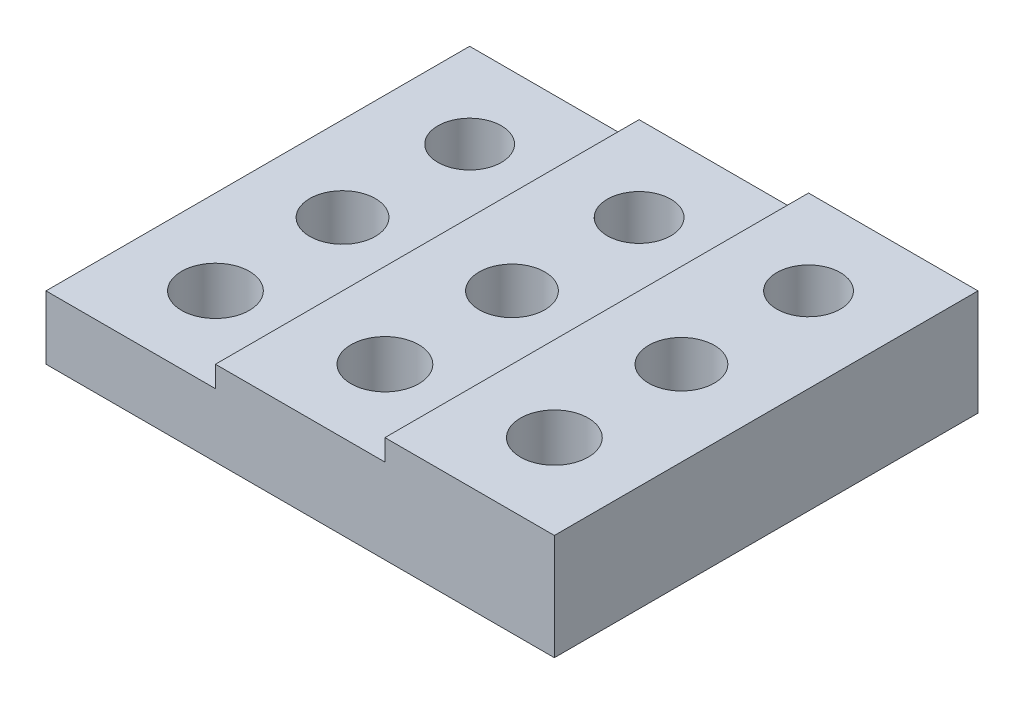
from build123d import *

# Parameters (mm, degrees)
SKETCH1_W           = 8
SKETCH1_H           = 20
SKETCH1_R           = 1.6
SKETCH1_R_2         = 1.55
SKETCH1_R_3         = 1.5
BOSS_EXTRUDE7_DEPTH = 5
SKETCH1_8_W         = 8
SKETCH1_8_H         = 20
SKETCH1_8_R         = 1.6
SKETCH1_8_R_2       = 1.55
SKETCH1_8_R_3       = 1.5
BOSS_EXTRUDE8_DEPTH = 4
SKETCH1_9_W         = 8
SKETCH1_9_H         = 20
SKETCH1_9_R         = 1.6
SKETCH1_9_R_2       = 1.55
SKETCH1_9_R_3       = 1.5
BOSS_EXTRUDE9_DEPTH = 3


with BuildPart() as part:
    # Sketch1 → Boss-Extrude7 (new body)
    with BuildSketch(Plane(origin=(0, 0, 0), x_dir=(1, 0, 0), z_dir=(0, 1, 0))):
        with Locations((12, 10)):
            Rectangle(SKETCH1_W, SKETCH1_H)
        with Locations((12, 4)):
            Circle(SKETCH1_R, mode=Mode.SUBTRACT)
        with Locations((12, 10)):
            Circle(SKETCH1_R_2, mode=Mode.SUBTRACT)
        with Locations((12, 16)):
            Circle(SKETCH1_R_3, mode=Mode.SUBTRACT)
    extrude(amount=BOSS_EXTRUDE7_DEPTH)

    # Sketch1_8 → Boss-Extrude8 (add)
    with BuildSketch(Plane(origin=(0, 0, 0), x_dir=(1, 0, 0), z_dir=(0, 1, 0))):
        with Locations((4, 10)):
            Rectangle(SKETCH1_8_W, SKETCH1_8_H)
        with Locations((4, 4)):
            Circle(SKETCH1_8_R, mode=Mode.SUBTRACT)
        with Locations((4, 10)):
            Circle(SKETCH1_8_R_2, mode=Mode.SUBTRACT)
        with Locations((4, 16)):
            Circle(SKETCH1_8_R_3, mode=Mode.SUBTRACT)
    extrude(amount=BOSS_EXTRUDE8_DEPTH)

    # Sketch1_9 → Boss-Extrude9 (add)
    with BuildSketch(Plane(origin=(0, 0, 0), x_dir=(1, 0, 0), z_dir=(0, 1, 0))):
        with Locations((-4, 10)):
            Rectangle(SKETCH1_9_W, SKETCH1_9_H)
        with Locations((-4, 4)):
            Circle(SKETCH1_9_R, mode=Mode.SUBTRACT)
        with Locations((-4, 10)):
            Circle(SKETCH1_9_R_2, mode=Mode.SUBTRACT)
        with Locations((-4, 16)):
            Circle(SKETCH1_9_R_3, mode=Mode.SUBTRACT)
    extrude(amount=BOSS_EXTRUDE9_DEPTH)


solid = part.part
